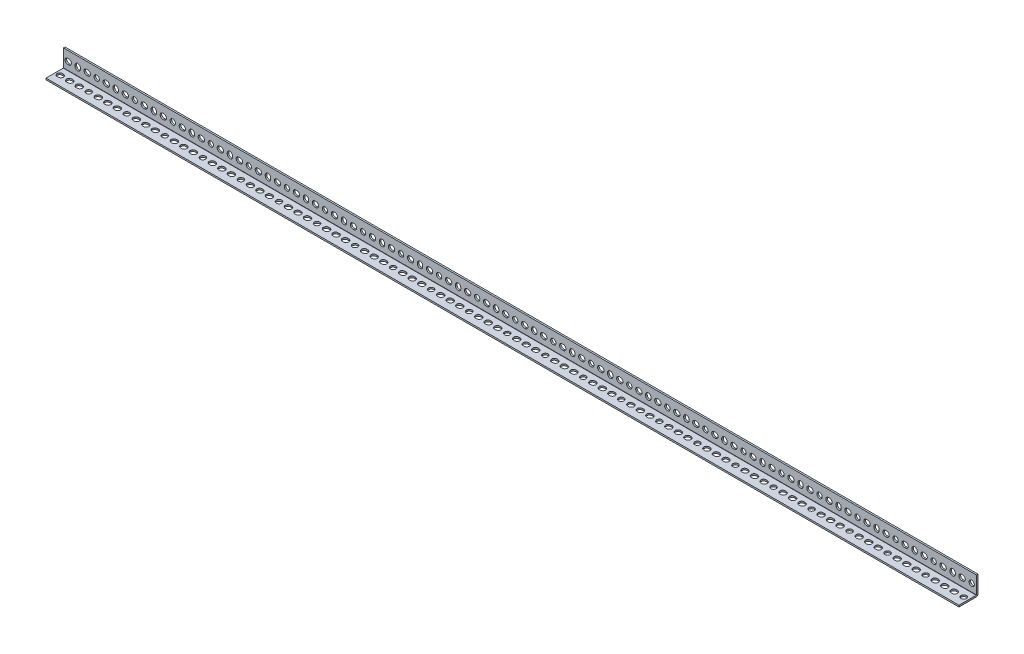
from build123d import *

# Parameters (mm, degrees)
BOSS_EXTRUDE1_DEPTH      = 914.4
BOSS_EXTRUDE1_DEPTH_BACK = 914.4
SKETCH5_R                = 5.334
CUT_EXTRUDE1_DEPTH       = 20.05
LPATTERN1_COUNT          = 25
LPATTERN1_PITCH          = 76.2
SKETCH6_R                = 5.334
CUT_EXTRUDE2_DEPTH       = 20.05
LPATTERN2_COUNT          = 25
LPATTERN2_PITCH          = 76.2


with BuildPart() as part:
    # Sketch4 → Boss-Extrude1 (new body, two sides)
    with BuildSketch(Plane(origin=(0, 0, 0), x_dir=(0, 0, -1), z_dir=(1, 0, 0))) as boss_extrude1_sk:
        with BuildLine():
            Line((-19.05, -15.875), (15.494, -15.875))
            ThreePointArc((15.494, -15.875), (15.763407684, -15.763407684), (15.875, -15.494))
            Line((15.875, -15.494), (15.875, 19.05))
            Line((15.875, 19.05), (19.05, 19.05))
            Line((19.05, 19.05), (19.05, -15.494))
            ThreePointArc((19.05, -15.494), (18.008471714, -18.008471714), (15.494, -19.05))
            Line((15.494, -19.05), (-19.05, -19.05))
            Line((-19.05, -19.05), (-19.05, -15.875))
        make_face()
    extrude(amount=BOSS_EXTRUDE1_DEPTH)
    extrude(boss_extrude1_sk.sketch, amount=-BOSS_EXTRUDE1_DEPTH_BACK)

    # Sketch5 → Cut-Extrude1 (cut, through all)
    with BuildSketch(Plane.XY):
        with Locations((904.875, 0)):
            Circle(SKETCH5_R)
        with BuildLine():
            Line((884.809, 5.334), (886.841, 5.334))
            ThreePointArc((886.841, 5.334), (892.175, 0), (886.841, -5.334))
            Line((886.841, -5.334), (884.809, -5.334))
            ThreePointArc((884.809, -5.334), (879.475, 0), (884.809, 5.334))
        make_face()
        with BuildLine():
            Line((872.109, 1.016), (872.109, -1.016))
            ThreePointArc((872.109, -1.016), (866.775, -6.35), (861.441, -1.016))
            Line((861.441, -1.016), (861.441, 1.016))
            ThreePointArc((861.441, 1.016), (866.775, 6.35), (872.109, 1.016))
        make_face()
        with BuildLine():
            Line((846.709, 5.334), (848.741, 5.334))
            ThreePointArc((848.741, 5.334), (854.075, 0), (848.741, -5.334))
            Line((848.741, -5.334), (846.709, -5.334))
            ThreePointArc((846.709, -5.334), (841.375, 0), (846.709, 5.334))
        make_face()
    cut_extrude1 = extrude(amount=-CUT_EXTRUDE1_DEPTH, mode=Mode.SUBTRACT)

    # LPattern1: Cut-Extrude1 ×25
    with Locations(*[(-i * LPATTERN1_PITCH, 0, 0) for i in range(1, LPATTERN1_COUNT)]):
        add(cut_extrude1, mode=Mode.SUBTRACT)

    # Sketch6 → Cut-Extrude2 (cut, through all)
    with BuildSketch(Plane(origin=(0, 0, 0), x_dir=(1, 0, 0), z_dir=(0, 1, 0))):
        with Locations((904.875, 0)):
            Circle(SKETCH6_R)
        with BuildLine():
            Line((884.809, 5.334), (886.841, 5.334))
            ThreePointArc((886.841, 5.334), (892.175, 0), (886.841, -5.334))
            Line((886.841, -5.334), (884.809, -5.334))
            ThreePointArc((884.809, -5.334), (879.475, 0), (884.809, 5.334))
        make_face()
        with BuildLine():
            Line((846.709, 5.334), (848.741, 5.334))
            ThreePointArc((848.741, 5.334), (854.075, 0), (848.741, -5.334))
            Line((848.741, -5.334), (846.709, -5.334))
            ThreePointArc((846.709, -5.334), (841.375, 0), (846.709, 5.334))
        make_face()
        with BuildLine():
            Line((865.759, 5.334), (867.791, 5.334))
            ThreePointArc((867.791, 5.334), (873.125, 0), (867.791, -5.334))
            Line((867.791, -5.334), (865.759, -5.334))
            ThreePointArc((865.759, -5.334), (860.425, 0), (865.759, 5.334))
        make_face()
    cut_extrude2 = extrude(amount=-CUT_EXTRUDE2_DEPTH, mode=Mode.SUBTRACT)

    # LPattern2: Cut-Extrude2 ×25
    with Locations(*[(-i * LPATTERN2_PITCH, 0, 0) for i in range(1, LPATTERN2_COUNT)]):
        add(cut_extrude2, mode=Mode.SUBTRACT)


solid = part.part
